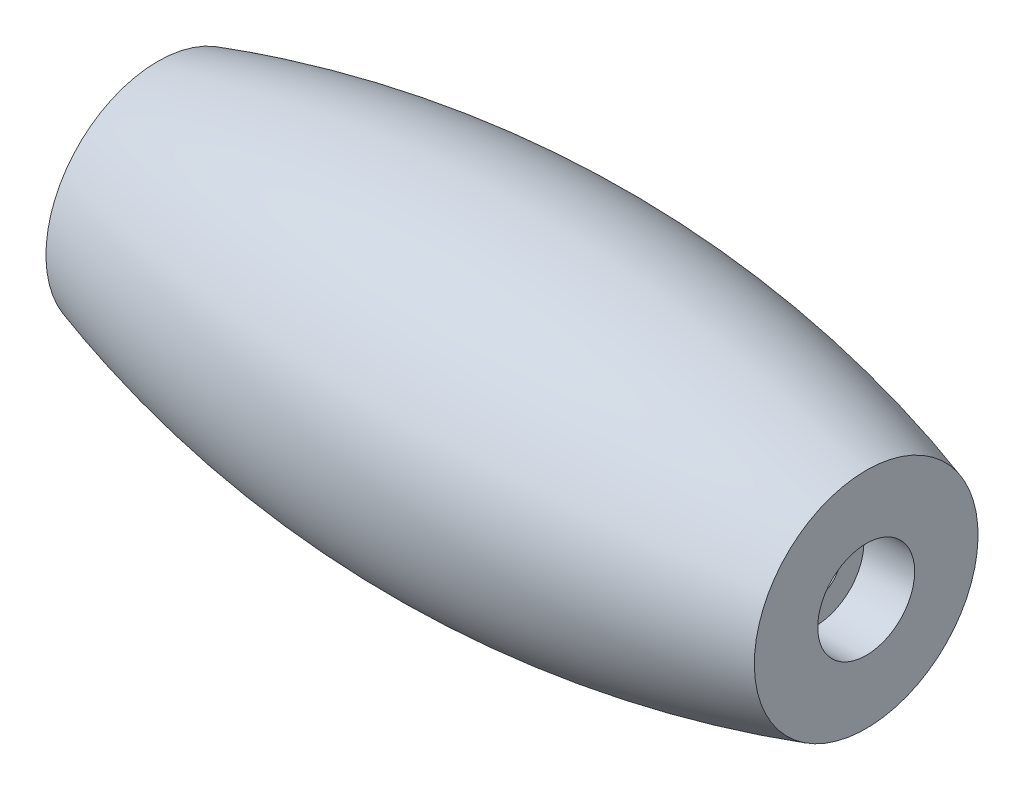
from build123d import *

# Parameters (mm, degrees)
CBORE_FOR_M3_HEX_SOCKET_HEAD_CAP_SCREW1_D           = 3.4
CBORE_FOR_M3_HEX_SOCKET_HEAD_CAP_SCREW1_DEPTH       = 11.57
CBORE_FOR_M3_HEX_SOCKET_HEAD_CAP_SCREW1_CBORE_D     = 6.5
CBORE_FOR_M3_HEX_SOCKET_HEAD_CAP_SCREW1_CBORE_DEPTH = 3.4
CBORE_FOR_M3_HEX_SOCKET_HEAD_CAP_SCREW1_TIP         = 1.021463052
CBORE_FOR_M3_HEX_SOCKET_HEAD_CAP_SCREW2_D           = 3.4
CBORE_FOR_M3_HEX_SOCKET_HEAD_CAP_SCREW2_DEPTH       = 11.57
CBORE_FOR_M3_HEX_SOCKET_HEAD_CAP_SCREW2_CBORE_D     = 6.5
CBORE_FOR_M3_HEX_SOCKET_HEAD_CAP_SCREW2_CBORE_DEPTH = 3.4
CBORE_FOR_M3_HEX_SOCKET_HEAD_CAP_SCREW2_TIP         = 1.021463052


with BuildPart() as part:
    # Sketch1 → Revolve1 (revolve)
    with BuildSketch(Plane.XY):
        with BuildLine():
            Line((0, 0), (0, 7.5))
            ThreePointArc((0, 7.5), (23.75, 11.106692047), (47.5, 7.5))
            Line((47.5, 7.5), (47.5, 0))
            Line((47.5, 0), (0, 0))
        make_face()
    revolve(axis=Axis((47.5, 0, 0), (-1, 0, 0)))

    # CBORE for M3 Hex Socket Head Cap Screw1
    with Locations(Plane(origin=(47.5, 0, 0), x_dir=(0, 0, -1), z_dir=(1, 0, 0))):
        with Locations((0, 0)):
            CounterBoreHole(CBORE_FOR_M3_HEX_SOCKET_HEAD_CAP_SCREW1_D / 2, CBORE_FOR_M3_HEX_SOCKET_HEAD_CAP_SCREW1_CBORE_D / 2, CBORE_FOR_M3_HEX_SOCKET_HEAD_CAP_SCREW1_CBORE_DEPTH, depth=CBORE_FOR_M3_HEX_SOCKET_HEAD_CAP_SCREW1_DEPTH)
            with Locations((0, 0, -(CBORE_FOR_M3_HEX_SOCKET_HEAD_CAP_SCREW1_DEPTH + CBORE_FOR_M3_HEX_SOCKET_HEAD_CAP_SCREW1_TIP / 2))):  # 118° drill point
                Cone(0, CBORE_FOR_M3_HEX_SOCKET_HEAD_CAP_SCREW1_D / 2, CBORE_FOR_M3_HEX_SOCKET_HEAD_CAP_SCREW1_TIP, mode=Mode.SUBTRACT)

    # CBORE for M3 Hex Socket Head Cap Screw2
    with Locations(Plane.ZY):
        with Locations((0, 0)):
            CounterBoreHole(CBORE_FOR_M3_HEX_SOCKET_HEAD_CAP_SCREW2_D / 2, CBORE_FOR_M3_HEX_SOCKET_HEAD_CAP_SCREW2_CBORE_D / 2, CBORE_FOR_M3_HEX_SOCKET_HEAD_CAP_SCREW2_CBORE_DEPTH, depth=CBORE_FOR_M3_HEX_SOCKET_HEAD_CAP_SCREW2_DEPTH)
            with Locations((0, 0, -(CBORE_FOR_M3_HEX_SOCKET_HEAD_CAP_SCREW2_DEPTH + CBORE_FOR_M3_HEX_SOCKET_HEAD_CAP_SCREW2_TIP / 2))):  # 118° drill point
                Cone(0, CBORE_FOR_M3_HEX_SOCKET_HEAD_CAP_SCREW2_D / 2, CBORE_FOR_M3_HEX_SOCKET_HEAD_CAP_SCREW2_TIP, mode=Mode.SUBTRACT)


solid = part.part
